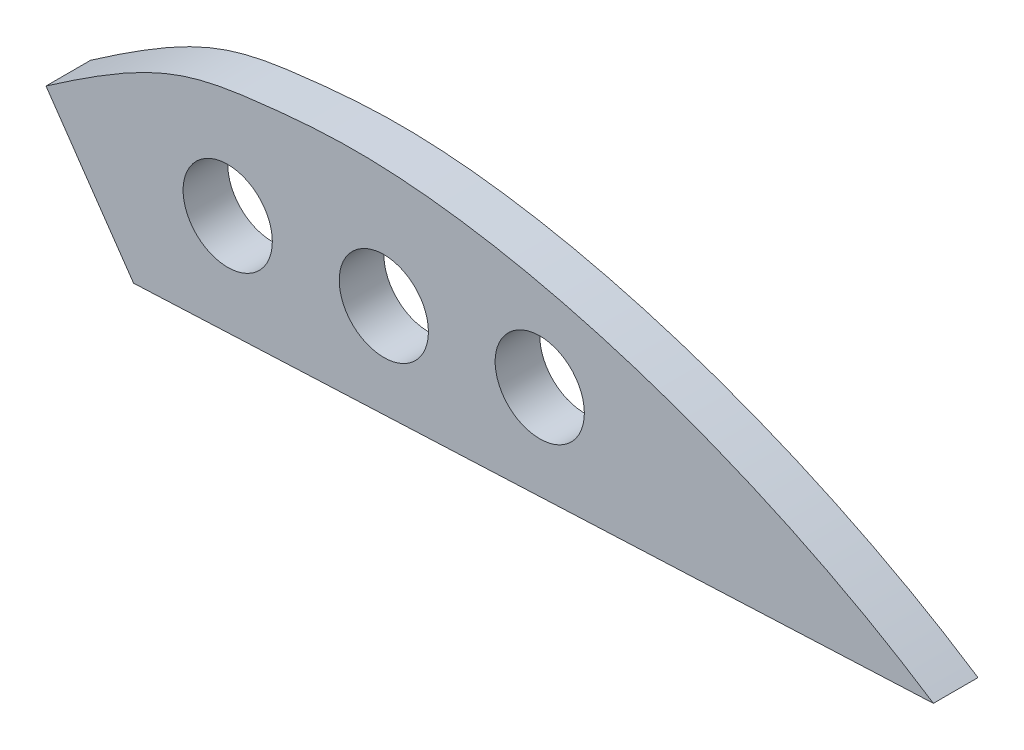
from build123d import *

# Parameters (mm, degrees)
SKETCH1_R           = 10
BOSS_EXTRUDE1_DEPTH = 10


with BuildPart() as part:
    # Sketch1 → Boss-Extrude1 (new body)
    with BuildSketch(Plane.XY):
        with BuildLine():
            Line((-1743.607960183, 593.830470178), (-1723.97557604, 565.354199265))
            Line((-1723.97557604, 565.354199265), (-1544.649956659, 573.44143308))
            add(Edge.make_bspline(
                [(-1743.607960183, 593.830470178), (-1719.507904213, 610.537812828), (-1709.389541143, 613.399774739), (-1646.280289738, 619.241808081), (-1585.716648888, 600.423930323), (-1544.649956659, 573.44143308)],
                knots=[0, 0, 0, 0, 0.320554642, 0.420554642, 1, 1, 1, 1], degree=3))
        make_face()
        with Locations((-1632.906290904, 590.670757295)):
            Circle(SKETCH1_R, mode=Mode.SUBTRACT)
        with Locations((-1667.865738011, 588.986400452)):
            Circle(SKETCH1_R, mode=Mode.SUBTRACT)
        with Locations((-1702.865738011, 588.986400452)):
            Circle(SKETCH1_R, mode=Mode.SUBTRACT)
    extrude(amount=BOSS_EXTRUDE1_DEPTH)


solid = part.part
